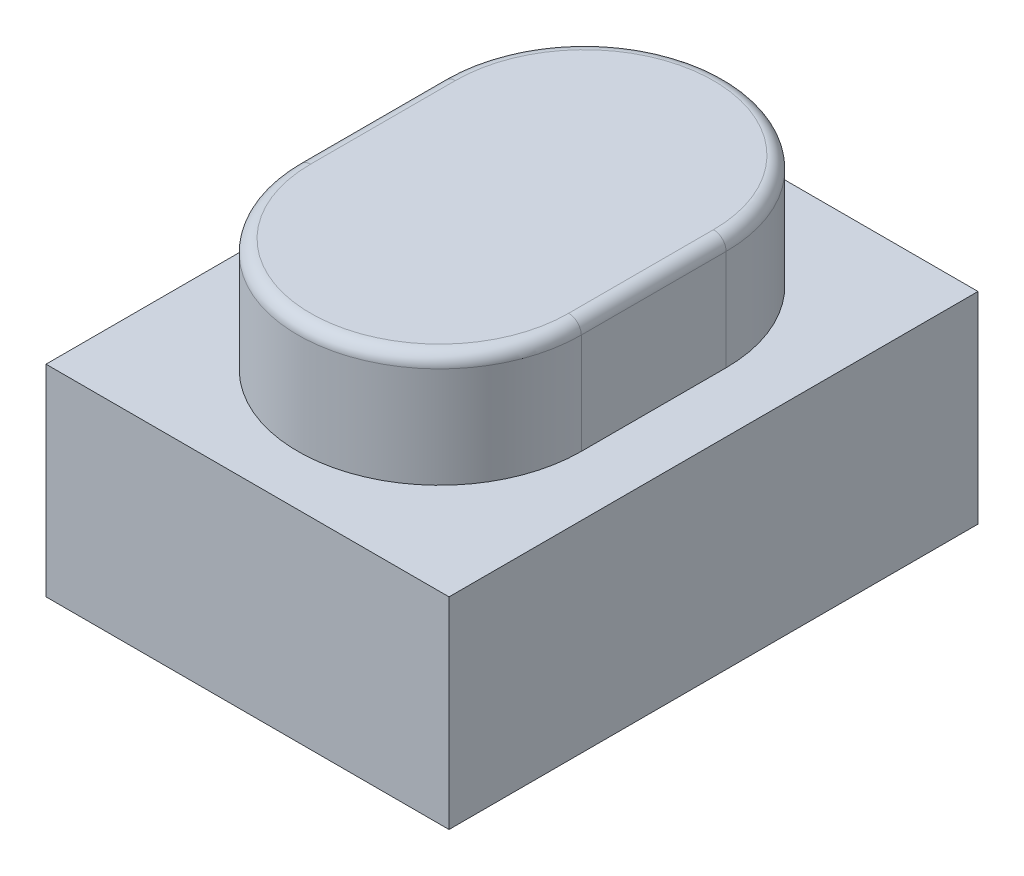
from build123d import *

# Parameters (mm, degrees)
BASES_W      = 3.2
BASES_H      = 4.2
BASE_DEPTH   = 1.6
BUTTON_DEPTH = 0.9
BF_R         = 0.1


with BuildPart() as part:
    # BaseS → Base (new body)
    with BuildSketch(Plane(origin=(0, 0, 0), x_dir=(1, 0, 0), z_dir=(0, 1, 0))):
        Rectangle(BASES_W, BASES_H)
    extrude(amount=BASE_DEPTH)

    # ButtonS → Button (add)
    with BuildSketch(Plane(origin=(0, 1.6, 0), x_dir=(1, 0, 0), z_dir=(0, 1, 0))):
        with BuildLine():
            Line((1.125, 0.575), (1.125, -0.575))
            ThreePointArc((1.125, -0.575), (0, -1.7), (-1.125, -0.575))
            Line((-1.125, -0.575), (-1.125, 0.575))
            ThreePointArc((-1.125, 0.575), (0, 1.7), (1.125, 0.575))
        make_face()
    extrude(amount=BUTTON_DEPTH)

    # BF
    bf_edges = [part.edges().sort_by_distance(p)[0] for p in [
        (0, 2.5, -1.7),
        (-1.125, 2.5, 0),
        (0, 2.5, 1.7),
        (1.125, 2.5, 0),
    ]]
    fillet(bf_edges, radius=BF_R)


solid = part.part
